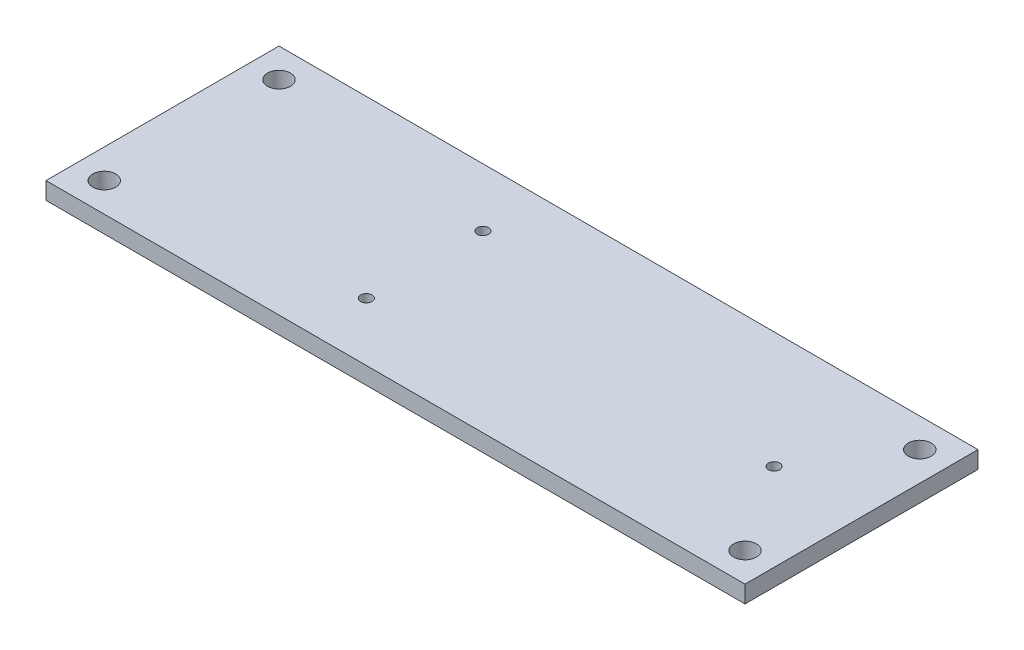
from build123d import *

# Parameters (mm, degrees)
SKETCH1_W           = 60.96
SKETCH1_H           = 20.32
SKETCH1_R           = 1
SKETCH1_R_2         = 0.5
BOSS_EXTRUDE1_DEPTH = 1.5


with BuildPart() as part:
    # Sketch1 → Boss-Extrude1 (new body)
    with BuildSketch(Plane(origin=(0, 0, 0), x_dir=(1, 0, 0), z_dir=(0, 1, 0))):
        with Locations((30.48, 10.16)):
            Rectangle(SKETCH1_W, SKETCH1_H)
        with Locations(Location((2.54, 2.54, 0), (0, 0, 270))):  # turned: the seam where the file's is
            Circle(SKETCH1_R, mode=Mode.SUBTRACT)
        with Locations(Location((58.42, 2.54, 0), (0, 0, 90))):  # turned: the seam where the file's is
            Circle(SKETCH1_R, mode=Mode.SUBTRACT)
        with Locations(Location((58.42, 17.78, 0), (0, 0, 270))):  # turned: the seam where the file's is
            Circle(SKETCH1_R, mode=Mode.SUBTRACT)
        with Locations(Location((2.54, 17.78, 0), (0, 0, 90))):  # turned: the seam where the file's is
            Circle(SKETCH1_R, mode=Mode.SUBTRACT)
        with Locations(Location((22.86, 5.08, 0), (0, 0, 270))):  # turned: the seam where the file's is
            Circle(SKETCH1_R_2, mode=Mode.SUBTRACT)
        with Locations(Location((53.34, 10.16, 0), (0, 0, 270))):  # turned: the seam where the file's is
            Circle(SKETCH1_R_2, mode=Mode.SUBTRACT)
        with Locations(Location((22.86, 15.24, 0), (0, 0, 90))):  # turned: the seam where the file's is
            Circle(SKETCH1_R_2, mode=Mode.SUBTRACT)
    extrude(amount=BOSS_EXTRUDE1_DEPTH)


solid = part.part
